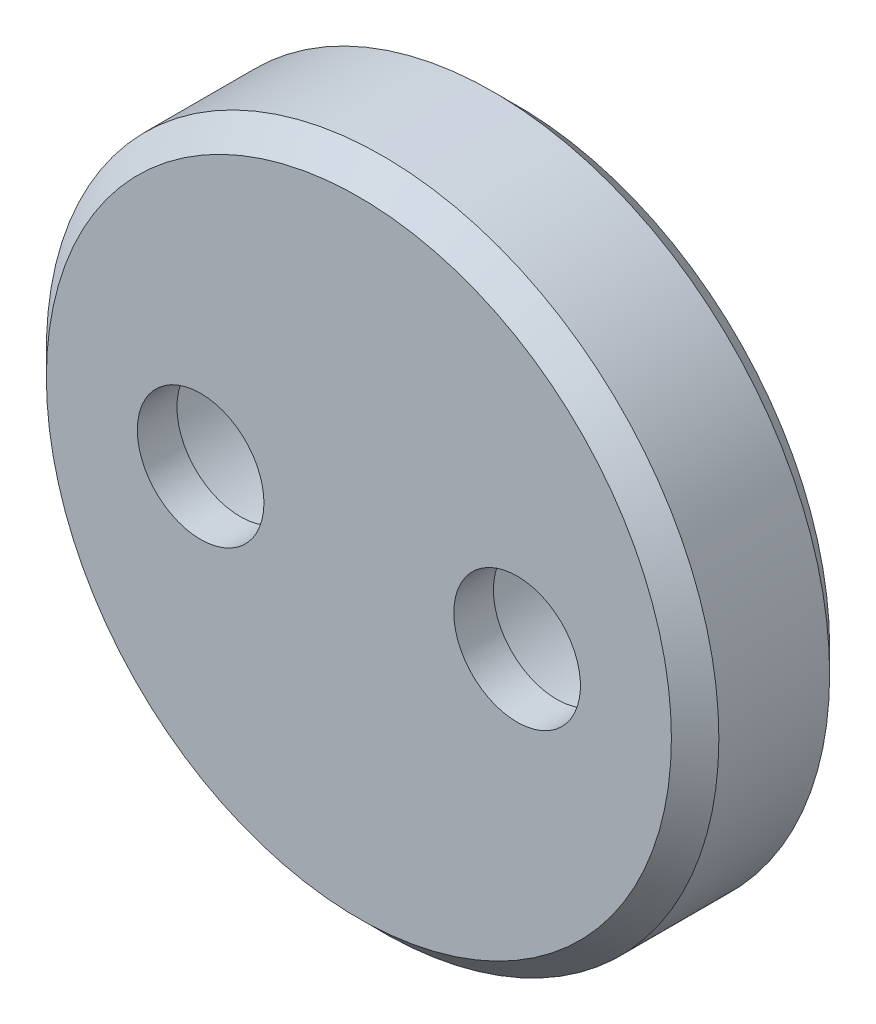
from build123d import *

# Parameters (mm, degrees)
ESQUISSE1_R             = 8.5
ESQUISSE1_R_2           = 1.6
BOSS_EXTRU_1_DEPTH      = 4
ESQUISSE3_R             = 2.9
ENL_V_MAT_EXTRU_1_DEPTH = 3
CHANFREIN1_SIZE         = 0.6


with BuildPart() as part:
    # Esquisse1 → Boss.-Extru.1 (new body)
    with BuildSketch(Plane.XY):
        Circle(ESQUISSE1_R)
        with Locations((-4, 0)):
            Circle(ESQUISSE1_R_2, mode=Mode.SUBTRACT)
        with Locations((4, 0)):
            Circle(ESQUISSE1_R_2, mode=Mode.SUBTRACT)
    extrude(amount=BOSS_EXTRU_1_DEPTH)

    # Esquisse3 → Enlèv. mat.-Extru.1 (cut)
    with BuildSketch(Plane(origin=(0, 0, 0), x_dir=(-1, 0, 0), z_dir=(0, 0, -1))):
        with Locations((4, 0)):
            Circle(ESQUISSE3_R)
        with Locations((-4, 0)):
            Circle(ESQUISSE3_R)
    extrude(amount=-ENL_V_MAT_EXTRU_1_DEPTH, mode=Mode.SUBTRACT)

    # Chanfrein1
    chanfrein1_edges = [part.edges().sort_by_distance(p)[0] for p in [
        (-8.5, 0, 0),
        (-8.5, 0, 4),
    ]]
    chamfer(chanfrein1_edges, length=CHANFREIN1_SIZE)


solid = part.part
